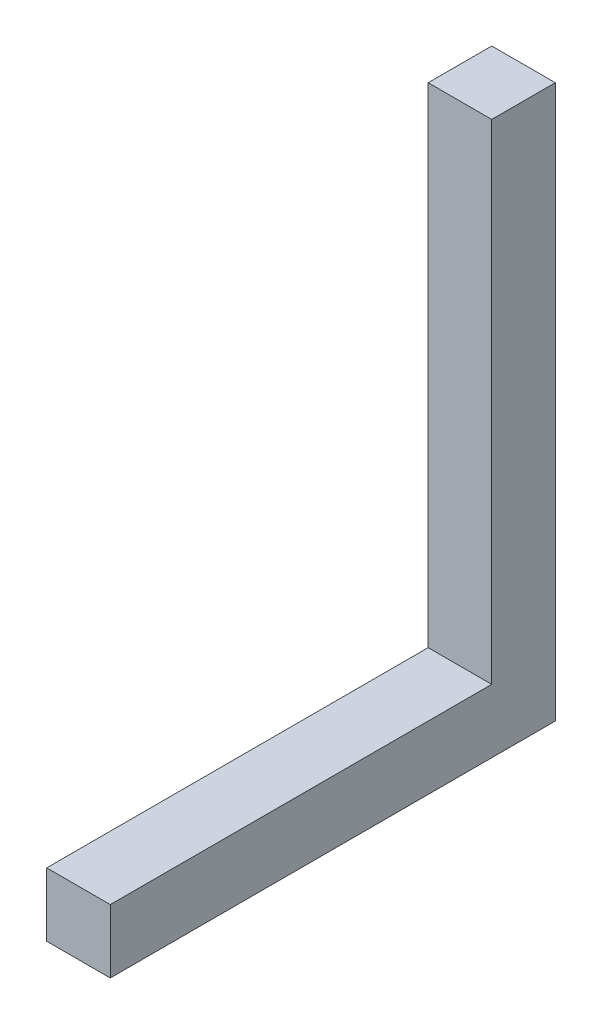
from build123d import *

# Parameters (mm, degrees)
SKETCH1_W           = 11.5
SKETCH1_H           = 11.5
BOSS_EXTRUDE1_DEPTH = 69
BOSS_EXTRUDE2_START = -5.75
SKETCH3_W           = 11.5
SKETCH3_H           = 11.5
BOSS_EXTRUDE2_DEPTH = 100


with BuildPart() as part:
    # Sketch1 → Boss-Extrude1 (new body)
    with BuildSketch(Plane.XY):
        Rectangle(SKETCH1_W, SKETCH1_H)
    extrude(amount=BOSS_EXTRUDE1_DEPTH)

    # Sketch3 → Boss-Extrude2 (add)
    with BuildSketch(Plane(origin=(0, 0, 0), x_dir=(1, 0, 0), z_dir=(0, 1, 0)).offset(BOSS_EXTRUDE2_START)):
        with Locations((0, 5.75)):
            Rectangle(SKETCH3_W, SKETCH3_H)
    extrude(amount=BOSS_EXTRUDE2_DEPTH)


solid = part.part
